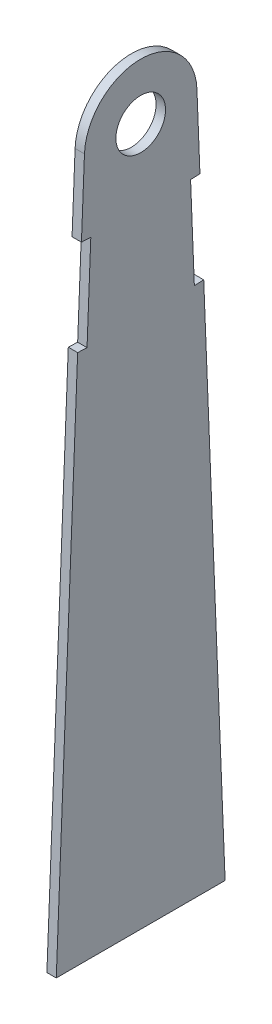
from build123d import *

# Parameters (mm, degrees)
BOSS_EXTRUDE1_DEPTH  = 1.5875
M8_CLEARANCE_HOLE1_D = 8.4


with BuildPart() as part:
    # Sketch1 → Boss-Extrude1 (new body)
    with BuildSketch(Plane(origin=(0, 0, 0), x_dir=(0, 0, -1), z_dir=(1, 0, 0))):
        with BuildLine():
            Line((-14.2875, -118.025122157), (0, -118.025122157))
            Line((0, -118.025122157), (14.2875, -118.025122157))
            Line((14.2875, -118.025122157), (10.667522727, -28.168425744))
            Line((10.667522727, -28.168425744), (9.081309394, -28.232328118))
            Line((9.081309394, -28.232328118), (8.442285655, -12.370194791))
            Line((8.442285655, -12.370194791), (10.028498987, -12.306292417))
            Line((10.028498987, -12.306292417), (9.517279996, 0.383414244))
            ThreePointArc((9.517279996, 0.383414244), (0, 9.525), (-9.517279996, 0.383414244))
            Line((-9.517279996, 0.383414244), (-10.028498987, -12.306292417))
            Line((-10.028498987, -12.306292417), (-8.442285655, -12.370194791))
            Line((-8.442285655, -12.370194791), (-9.081309394, -28.232328118))
            Line((-9.081309394, -28.232328118), (-10.667522727, -28.168425744))
            Line((-10.667522727, -28.168425744), (-14.2875, -118.025122157))
        make_face()
    extrude(amount=BOSS_EXTRUDE1_DEPTH)

    # M8 Clearance Hole1 (through all)
    with Locations(Plane(origin=(1.5875, 0, 0), x_dir=(0, 0, -1), z_dir=(1, 0, 0))):
        with Locations((0, 0)):
            Hole(M8_CLEARANCE_HOLE1_D / 2)


solid = part.part
